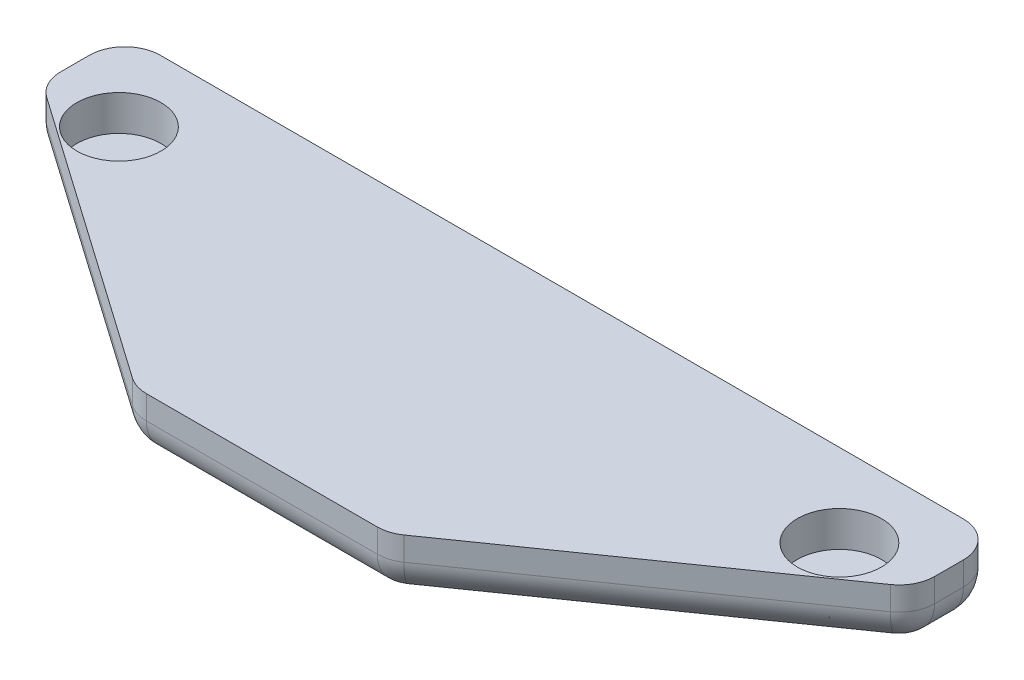
from build123d import *

# Parameters (mm, degrees)
BOSS_EXTRUDE1_DEPTH = 2.5
SKETCH2_R           = 1.78
CUT_EXTRUDE1_DEPTH  = 1.5
FILLET1_R           = 1.5


with BuildPart() as part:
    # Sketch1 → Boss-Extrude1 (new body)
    with BuildSketch(Plane(origin=(0, 0, 0), x_dir=(1, 0, 0), z_dir=(0, 1, 0))):
        Polygon((-21.216153836, 11.741903429), (-21.216153836, 8.241903429), (-8.076153836, -0.958096571), (-2.716153836, -0.958096571), (-2.716153836, 11.741903429), align=None)
    extrude(amount=BOSS_EXTRUDE1_DEPTH)

    # Sketch2 → Cut-Extrude1 (cut)
    with BuildSketch(Plane(origin=(0, 2.5, 0), x_dir=(1, 0, 0), z_dir=(0, 1, 0))):
        with Locations((-17.966153836, 8.241903429)):
            Circle(SKETCH2_R)
    extrude(amount=-CUT_EXTRUDE1_DEPTH, mode=Mode.SUBTRACT)

    # Fillet1
    fillet1_edges = [part.edges().sort_by_distance(p)[0] for p in [
        (-5.396153836, 0, 0.958096571),
        (-14.646153836, 0, -3.641903429),
        (-21.216153836, 0, -9.991903429),
        (-11.966153836, 0, -11.741903429),
        (-8.076153836, 1.25, 0.958096571),
        (-21.216153836, 1.25, -8.241903429),
        (-21.216153836, 1.25, -11.741903429),
    ]]
    fillet(fillet1_edges, radius=FILLET1_R)

    # Mirror1: part across plane


with BuildPart() as part_1:
    add(part.part)
    add(part.part.mirror(Plane(origin=(-2.716153836, 2.5, 0.958096571), x_dir=(0, 0, 1), z_dir=(-1, 0, 0))))


solid = part_1.part
